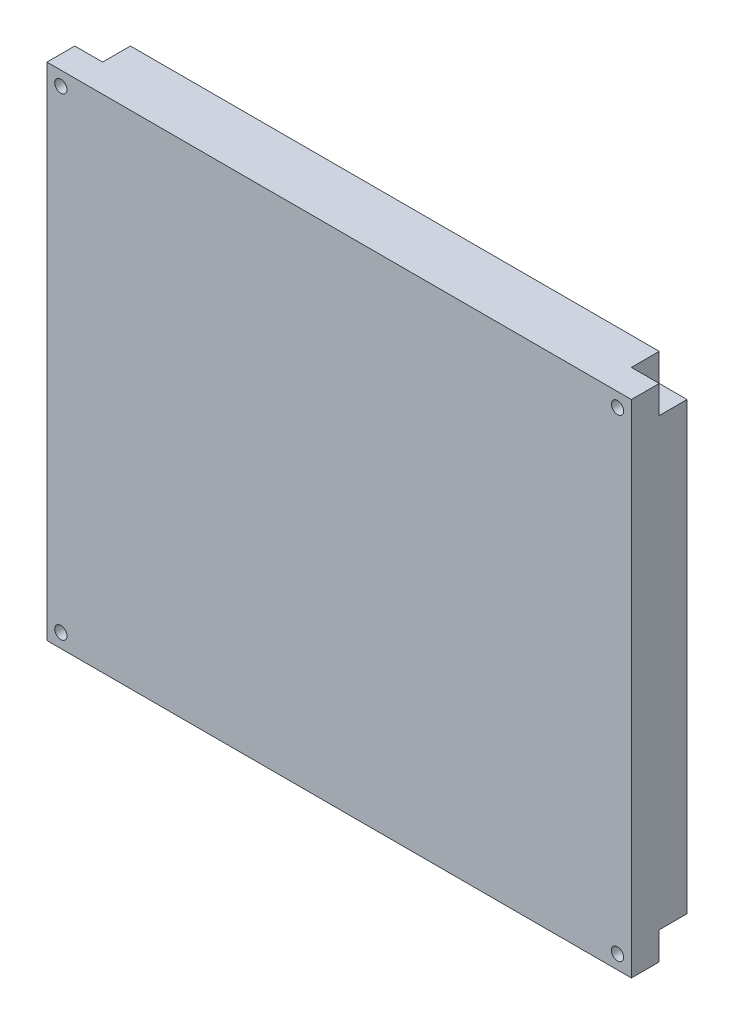
from build123d import *

# Parameters (mm, degrees)
SKETCH_1_W          = 105
SKETCH_1_H          = 90
EXTRUDE_1_DEPTH     = 10
SKETCH_3_W          = 5
SKETCH_3_H          = 5
CUT_EXTRUDE_1_DEPTH = 5
SKETCH_4_R          = 1.1
CUT_EXTRUDE_2_DEPTH = 33.2


with BuildPart() as part:
    # 草圖1 → 填料-伸長1 (new body)
    with BuildSketch(Plane.XY):
        with Locations((-6.538461538, -15.192307692)):
            Rectangle(SKETCH_1_W, SKETCH_1_H)
    extrude(amount=EXTRUDE_1_DEPTH)

    # 草圖3 → 除料-伸長1 (cut)
    with BuildSketch(Plane.XY):
        with Locations((43.461538462, -57.692307692)):
            Rectangle(SKETCH_3_W, SKETCH_3_H)
        with Locations((-56.538461538, -57.692307692)):
            Rectangle(SKETCH_3_W, SKETCH_3_H)
        with Locations((43.461538462, 27.307692308)):
            Rectangle(SKETCH_3_W, SKETCH_3_H)
        with Locations((-56.538461538, 27.307692308)):
            Rectangle(SKETCH_3_W, SKETCH_3_H)
    extrude(amount=CUT_EXTRUDE_1_DEPTH, mode=Mode.SUBTRACT)

    # 草圖4 → 除料-伸長2 (cut)
    with BuildSketch(Plane.XY):
        with Locations((-56.538461538, -57.692307692)):
            Circle(SKETCH_4_R)
        with Locations((43.461538462, -57.692307692)):
            Circle(SKETCH_4_R)
        with Locations((43.461538462, 27.307692308)):
            Circle(SKETCH_4_R)
        with Locations((-56.538461538, 27.307692308)):
            Circle(SKETCH_4_R)
    extrude(amount=CUT_EXTRUDE_2_DEPTH, mode=Mode.SUBTRACT)


solid = part.part
